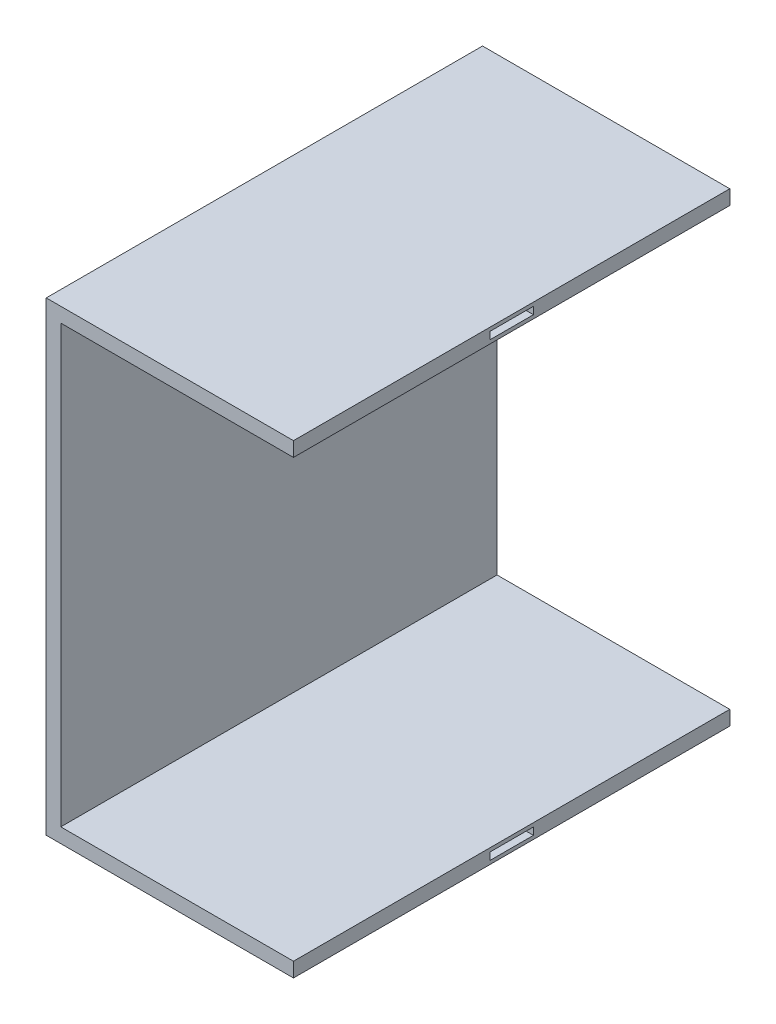
from build123d import *

# Parameters (mm, degrees)
BOSS_EXTRUDE1_DEPTH = 15
SKETCH3_W           = 3
SKETCH3_H           = 0.5
CUT_EXTRUDE1_DEPTH  = 1
SKETCH2_W           = 3
SKETCH2_H           = 0.5
CUT_EXTRUDE2_DEPTH  = 1
SKETCH5_R           = 0.5
CUT_EXTRUDE3_DEPTH  = 0.25


with BuildPart() as part:
    # Sketch1 → Boss-Extrude1 (new body, symmetric)
    with BuildSketch(Plane.XY):
        Polygon((0, 0), (17, 0), (17, 1), (1, 1), (1, 31), (17, 31), (17, 32), (0, 32), align=None)
    extrude(amount=BOSS_EXTRUDE1_DEPTH, both=True)

    # Sketch3 → Cut-Extrude1 (cut)
    with BuildSketch(Plane(origin=(17, 0, 0), x_dir=(0, 0, -1), z_dir=(1, 0, 0))):
        with Locations((0, 0.495)):
            Rectangle(SKETCH3_W, SKETCH3_H)
    extrude(amount=-CUT_EXTRUDE1_DEPTH, mode=Mode.SUBTRACT)

    # Sketch2 → Cut-Extrude2 (cut)
    with BuildSketch(Plane(origin=(17, 0, 0), x_dir=(0, 0, -1), z_dir=(1, 0, 0))):
        with Locations((0, 31.5)):
            Rectangle(SKETCH2_W, SKETCH2_H)
    extrude(amount=-CUT_EXTRUDE2_DEPTH, mode=Mode.SUBTRACT)

    # Sketch5 → Cut-Extrude3 (cut, symmetric)
    with BuildSketch(Plane.ZY):
        with Locations((0, 16)):
            Circle(SKETCH5_R)
    extrude(amount=CUT_EXTRUDE3_DEPTH, both=True, mode=Mode.SUBTRACT)


solid = part.part
